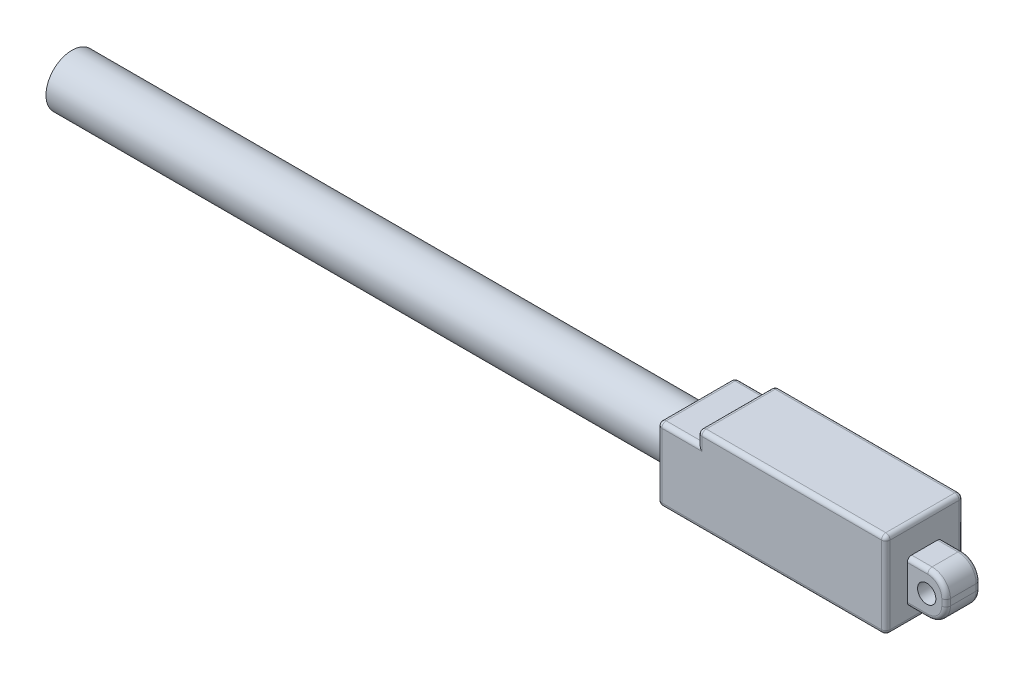
from build123d import *

# Parameters (mm, degrees)
BASE_DEPTH       = 18
MOUNT_DEPTH      = 4
MOUNT_DEPTH_BACK = 4
SKETCH2_R        = 2.125
SKETCH3_R        = 6
TUBE_DEPTH       = 145
FILLET1_R        = 1


with BuildPart() as part:
    # Sketch1 → Base (new body)
    with BuildSketch(Plane.XY):
        Polygon((0, 0), (53, 0), (53, 20), (9.30875576, 20), (9.30875576, 17), (0, 17), align=None)
    extrude(amount=BASE_DEPTH)

    # Sketch2 → Mount (add, two sides: drawn at the far end of the back side and taken through both)
    with BuildSketch(Plane.XY.offset(9).offset(-MOUNT_DEPTH_BACK)):
        with BuildLine():
            Line((53, 13.5), (57.75, 13.5))
            ThreePointArc((57.75, 13.5), (60.75520382, 12.25520382), (62, 9.25))
            Line((62, 9.25), (62, 7.75))
            ThreePointArc((62, 7.75), (60.75520382, 4.74479618), (57.75, 3.5))
            Line((57.75, 3.5), (53, 3.5))
            Line((53, 3.5), (53, 13.5))
        make_face()
        with Locations((57.5, 8.5)):
            Circle(SKETCH2_R, mode=Mode.SUBTRACT)
    extrude(amount=MOUNT_DEPTH + MOUNT_DEPTH_BACK)

    # Sketch3 → Tube (add)
    with BuildSketch(Plane.ZY):
        with Locations((9, 8.5)):
            Circle(SKETCH3_R)
    extrude(amount=TUBE_DEPTH)

    # Fillet1
    fillet1_edges = [part.edges().sort_by_distance(p)[0] for p in [
        (55.375, 3.5, 5),
        (60.75520382, 4.74479618, 5),
        (62, 8.5, 5),
        (55.375, 13.5, 5),
        (55.375, 3.5, 13),
        (60.75520382, 4.74479618, 13),
        (62, 8.5, 13),
        (55.375, 13.5, 13),
        (60.75520382, 12.25520382, 5),
        (60.75520382, 12.25520382, 13),
        (0, 17, 9),
        (0, 0, 9),
        (53, 20, 9),
        (9.30875576, 20, 9),
        (26.5, 0, 0),
        (53, 10, 0),
        (31.15437788, 20, 0),
        (9.30875576, 18.5, 0),
        (4.65437788, 17, 0),
        (0, 8.5, 0),
        (4.65437788, 17, 18),
        (9.30875576, 18.5, 18),
        (31.15437788, 20, 18),
        (53, 10, 18),
        (26.5, 0, 18),
        (0, 8.5, 18),
        (53, 0, 9),
    ]]
    fillet(fillet1_edges, radius=FILLET1_R)


solid = part.part
